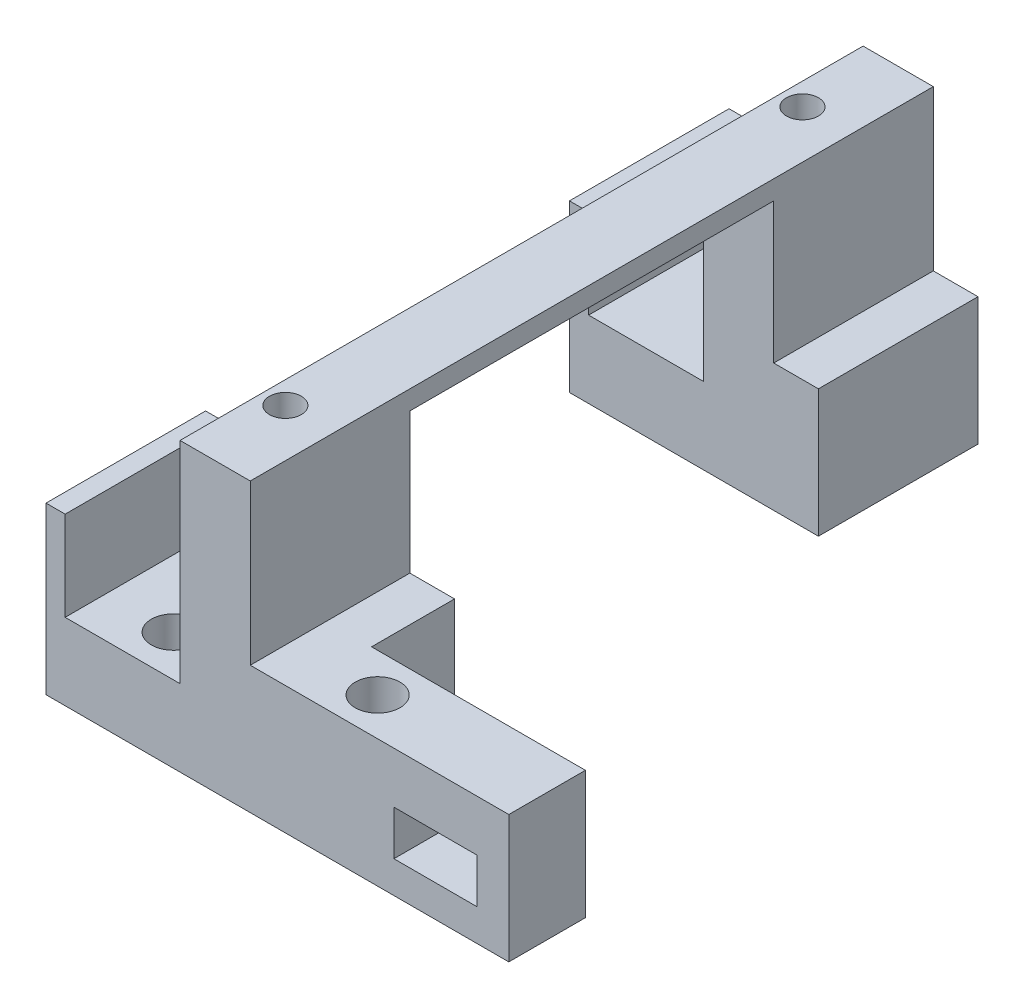
from build123d import *

# Parameters (mm, degrees)
SALIENTE_EXTRUIR1_DEPTH = 107
CROQUIS3_W              = 57
CROQUIS3_H              = 42
CORTAR_EXTRUIR1_DEPTH   = 39
CORTAR_EXTRUIR2_REACH   = 47
CROQUIS2_R              = 2.5
CORTAR_EXTRUIR3_REACH   = 14
CROQUIS4_R              = 3.5
CROQUIS5_W              = 12
CROQUIS5_H              = 20
SALIENTE_EXTRUIR2_DEPTH = 33.5
CORTAR_EXTRUIR4_REACH   = 22
CROQUIS7_R              = 3.5
CORTAR_EXTRUIR5_REACH   = 109
CROQUIS8_W              = 13
CROQUIS8_H              = 7


with BuildPart() as part:
    # Croquis1 → Saliente-Extruir1 (new body)
    with BuildSketch(Plane.XY):
        Polygon((0, 0), (39, 0), (39, 20), (32, 20), (32, 45), (21, 45), (21, 12), (3, 12), (3, 26), (0, 26), align=None)
    extrude(amount=SALIENTE_EXTRUIR1_DEPTH)

    # Croquis3 → Cortar-Extruir1 (cut)
    with BuildSketch(Plane.ZY):
        with Locations((53.5, 21)):
            Rectangle(CROQUIS3_W, CROQUIS3_H)
    extrude(amount=-CORTAR_EXTRUIR1_DEPTH, mode=Mode.SUBTRACT)

    # Croquis2 → Cortar-Extruir2 (cut, up to next)
    with BuildSketch(Plane(origin=(0, 45, 0), x_dir=(1, 0, 0), z_dir=(0, 1, 0)), mode=Mode.PRIVATE) as cortar_extruir2_sk1:
        with Locations((24.5, -94)):
            Circle(CROQUIS2_R)
    cortar_extruir2_tool1 = extrude(cortar_extruir2_sk1.sketch, amount=-CORTAR_EXTRUIR2_REACH, mode=Mode.PRIVATE) & part.part
    add(cortar_extruir2_tool1.solids().sort_by_distance((24.5, 45, 94))[0], mode=Mode.SUBTRACT)
    # Croquis2 → Cortar-Extruir2 (cut, up to next)
    with BuildSketch(Plane(origin=(0, 45, 0), x_dir=(1, 0, 0), z_dir=(0, 1, 0)), mode=Mode.PRIVATE) as cortar_extruir2_sk2:
        with Locations((24.5, -13)):
            Circle(CROQUIS2_R)
    cortar_extruir2_tool2 = extrude(cortar_extruir2_sk2.sketch, amount=-CORTAR_EXTRUIR2_REACH, mode=Mode.PRIVATE) & part.part
    add(cortar_extruir2_tool2.solids().sort_by_distance((24.5, 45, 13))[0], mode=Mode.SUBTRACT)

    # Croquis4 → Cortar-Extruir3 (cut, up to next)
    with BuildSketch(Plane(origin=(0, 12, 0), x_dir=(1, 0, 0), z_dir=(0, 1, 0)), mode=Mode.PRIVATE) as cortar_extruir3_sk1:
        with Locations((13.5, -100.5)):
            Circle(CROQUIS4_R)
    cortar_extruir3_tool1 = extrude(cortar_extruir3_sk1.sketch, amount=-CORTAR_EXTRUIR3_REACH, mode=Mode.PRIVATE) & part.part
    add(cortar_extruir3_tool1.solids().sort_by_distance((13.5, 12, 100.5))[0], mode=Mode.SUBTRACT)
    # Croquis4 → Cortar-Extruir3 (cut, up to next)
    with BuildSketch(Plane(origin=(0, 12, 0), x_dir=(1, 0, 0), z_dir=(0, 1, 0)), mode=Mode.PRIVATE) as cortar_extruir3_sk2:
        with Locations((13.5, -6.5)):
            Circle(CROQUIS4_R)
    cortar_extruir3_tool2 = extrude(cortar_extruir3_sk2.sketch, amount=-CORTAR_EXTRUIR3_REACH, mode=Mode.PRIVATE) & part.part
    add(cortar_extruir3_tool2.solids().sort_by_distance((13.5, 12, 6.5))[0], mode=Mode.SUBTRACT)

    # Croquis5 → Saliente-Extruir2 (add)
    with BuildSketch(Plane(origin=(39, 0, 0), x_dir=(0, 0, -1), z_dir=(1, 0, 0))):
        with Locations((-101, 10)):
            Rectangle(CROQUIS5_W, CROQUIS5_H)
    extrude(amount=SALIENTE_EXTRUIR2_DEPTH)

    # Croquis7 → Cortar-Extruir4 (cut, up to next)
    with BuildSketch(Plane(origin=(0, 20, 0), x_dir=(1, 0, 0), z_dir=(0, 1, 0)), mode=Mode.PRIVATE) as cortar_extruir4_sk1:
        with Locations((46, -101.053923336)):
            Circle(CROQUIS7_R)
    cortar_extruir4_tool1 = extrude(cortar_extruir4_sk1.sketch, amount=-CORTAR_EXTRUIR4_REACH, mode=Mode.PRIVATE) & part.part
    add(cortar_extruir4_tool1.solids().sort_by_distance((46, 20, 101.053923))[0], mode=Mode.SUBTRACT)

    # Croquis8 → Cortar-Extruir5 (cut, up to next)
    with BuildSketch(Plane.XY.offset(107), mode=Mode.PRIVATE) as cortar_extruir5_sk1:
        with Locations((61, 8.5)):
            Rectangle(CROQUIS8_W, CROQUIS8_H)
    cortar_extruir5_tool1 = extrude(cortar_extruir5_sk1.sketch, amount=-CORTAR_EXTRUIR5_REACH, mode=Mode.PRIVATE) & part.part
    add(cortar_extruir5_tool1.solids().sort_by_distance((61, 8.5, 107))[0], mode=Mode.SUBTRACT)


solid = part.part
